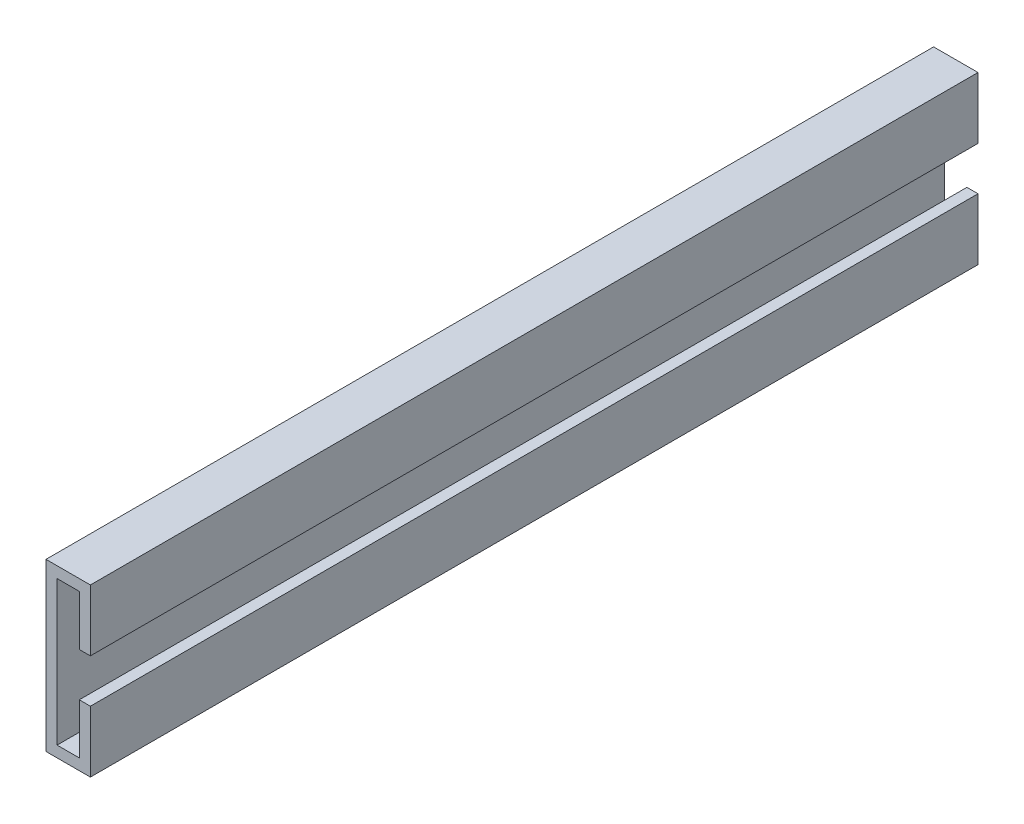
from build123d import *

# Parameters (mm, degrees)
BOSS_EXTRUDE1_DEPTH = 400


with BuildPart() as part:
    # Sketch1 → Boss-Extrude1 (new body, symmetric)
    with BuildSketch(Plane.XY):
        Polygon((0, -65), (0, 65), (20, 65), (20, 19.642264487), (30, 19.642264487), (30, 75), (-10, 75), (-10, -75), (30, -75), (30, -19.642264487), (20, -19.642264487), (20, -65), align=None)
    extrude(amount=BOSS_EXTRUDE1_DEPTH, both=True)


solid = part.part
